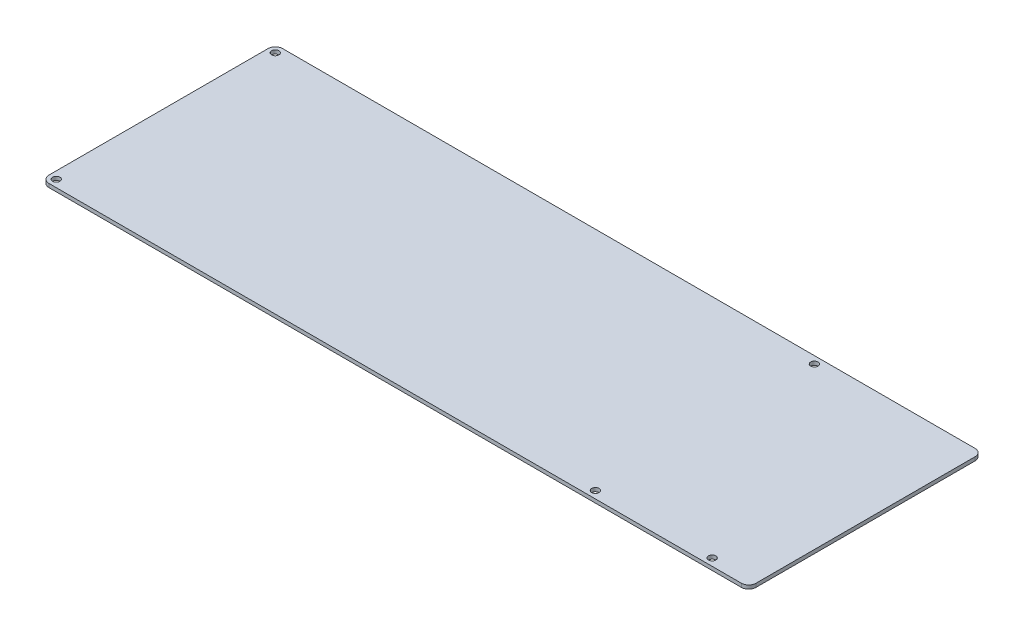
from build123d import *

# Parameters (mm, degrees)
SKETCH1_W           = 614.97
SKETCH1_H           = 203.2
SKETCH1_R           = 3.175
BOSS_EXTRUDE1_DEPTH = 3.175
FILLET1_R           = 6.35


with BuildPart() as part:
    # Sketch1 → Boss-Extrude1 (new body)
    with BuildSketch(Plane(origin=(0, 0, 0), x_dir=(1, 0, 0), z_dir=(0, 1, 0))):
        with Locations((-347.095055786, 167.356642248)):
            Rectangle(SKETCH1_W, SKETCH1_H)
        with Locations(Location((-77.710055786, 72.106642248, 0), (0, 0, 270))):
            Circle(SKETCH1_R, mode=Mode.SUBTRACT)
        with Locations(Location((-179.310055786, 262.606642248, 0), (0, 0, 270))):
            Circle(SKETCH1_R, mode=Mode.SUBTRACT)
        with Locations(Location((-179.310055786, 72.106642248, 0), (0, 0, 270))):
            Circle(SKETCH1_R, mode=Mode.SUBTRACT)
        with Locations((-45.960055786, 72.106642248)):
            Circle(SKETCH1_R, mode=Mode.SUBTRACT)
        with Locations((-45.960055786, 262.606642248)):
            Circle(SKETCH1_R, mode=Mode.SUBTRACT)
        with Locations(Location((-648.230055786, 72.106642248, 0), (0, 0, 270))):
            Circle(SKETCH1_R, mode=Mode.SUBTRACT)
        with Locations(Location((-648.230055786, 262.606642248, 0), (0, 0, 270))):
            Circle(SKETCH1_R, mode=Mode.SUBTRACT)
        with Locations((-45.960055786, 72.106642248)):
            Circle(SKETCH1_R)
        with Locations((-45.960055786, 262.606642248)):
            Circle(SKETCH1_R)
    extrude(amount=-BOSS_EXTRUDE1_DEPTH)

    # Fillet1
    fillet1_edges = [part.edges().sort_by_distance(p)[0] for p in [
        (-654.580055786, -1.5875, -65.756642248),
        (-654.580055786, -1.5875, -268.956642248),
        (-39.610055786, -1.5875, -268.956642248),
        (-39.610055786, -1.5875, -65.756642248),
    ]]
    fillet(fillet1_edges, radius=FILLET1_R)


solid = part.part
